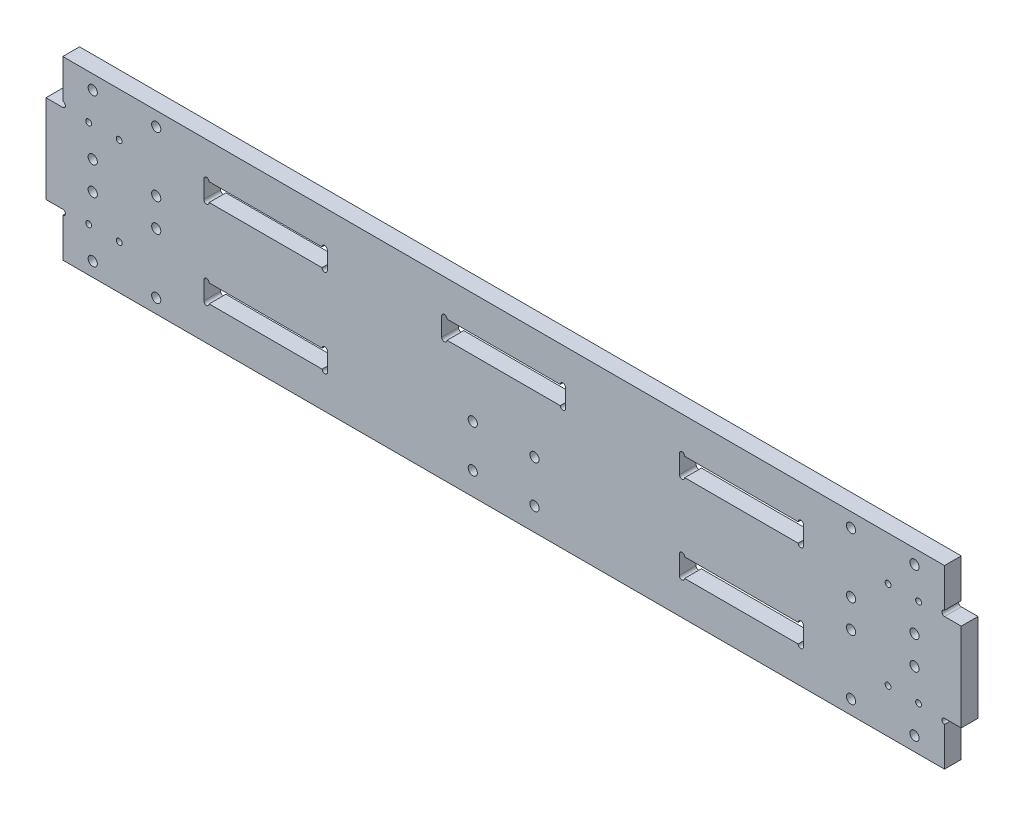
from build123d import *

# Parameters (mm, degrees)
SKETCH1_R                  = 2.6
SKETCH1_W                  = 70
SKETCH1_H                  = 10.2
SKETCH1_W_2                = 70.1
SKETCH1_H_2                = 10.3
SKETCH1_W_3                = 70.2
SKETCH1_H_3                = 10.4
SKETCH1_W_4                = 70.3
SKETCH1_H_4                = 10.5
SKETCH1_W_5                = 70.4
SKETCH1_H_5                = 10.6
BOSS_EXTRUDE1_DEPTH        = 9.5
F_3_3_3_3_DIAMETER_HOLE1_D = 3.3
F_3_0_3_DIAMETER_HOLE1_D   = 3


with BuildPart() as part:
    # Sketch1 → Boss-Extrude1 (new body)
    with BuildSketch(Plane.XY):
        Polygon((-250, -25), (-259.5, -25), (-259.5, 25), (-250, 25), (-250, 50), (250, 50), (250, 25), (259.5, 25), (259.5, -25), (250, -25), (250, -50), (-250, -50), align=None)
        with Locations((-233, -42)):
            Circle(SKETCH1_R, mode=Mode.SUBTRACT)
        with Locations((-197, -42)):
            Circle(SKETCH1_R, mode=Mode.SUBTRACT)
        with Locations((-197, -8)):
            Circle(SKETCH1_R, mode=Mode.SUBTRACT)
        with Locations((-233, -8)):
            Circle(SKETCH1_R, mode=Mode.SUBTRACT)
        with Locations((-197, 42)):
            Circle(SKETCH1_R, mode=Mode.SUBTRACT)
        with Locations((-197, 8)):
            Circle(SKETCH1_R, mode=Mode.SUBTRACT)
        with Locations((-233, 8)):
            Circle(SKETCH1_R, mode=Mode.SUBTRACT)
        with Locations((-233, 42)):
            Circle(SKETCH1_R, mode=Mode.SUBTRACT)
        with Locations((233, 42)):
            Circle(SKETCH1_R, mode=Mode.SUBTRACT)
        with Locations((233, 8)):
            Circle(SKETCH1_R, mode=Mode.SUBTRACT)
        with Locations((197, 8)):
            Circle(SKETCH1_R, mode=Mode.SUBTRACT)
        with Locations((197, 42)):
            Circle(SKETCH1_R, mode=Mode.SUBTRACT)
        with Locations((233, -8)):
            Circle(SKETCH1_R, mode=Mode.SUBTRACT)
        with Locations((197, -8)):
            Circle(SKETCH1_R, mode=Mode.SUBTRACT)
        with Locations((197, -42)):
            Circle(SKETCH1_R, mode=Mode.SUBTRACT)
        with Locations((233, -42)):
            Circle(SKETCH1_R, mode=Mode.SUBTRACT)
        with Locations((-17.5, -37)):
            Circle(SKETCH1_R, mode=Mode.SUBTRACT)
        with Locations((17.5, -37)):
            Circle(SKETCH1_R, mode=Mode.SUBTRACT)
        with Locations((17.5, -13)):
            Circle(SKETCH1_R, mode=Mode.SUBTRACT)
        with Locations((-17.5, -13)):
            Circle(SKETCH1_R, mode=Mode.SUBTRACT)
        with Locations((-135, 24.9)):
            Rectangle(SKETCH1_W, SKETCH1_H, mode=Mode.SUBTRACT)
        with Locations((-134.95, -24.85)):
            Rectangle(SKETCH1_W_2, SKETCH1_H_2, mode=Mode.SUBTRACT)
        with Locations((0, 24.8)):
            Rectangle(SKETCH1_W_3, SKETCH1_H_3, mode=Mode.SUBTRACT)
        with Locations((134.85, 24.75)):
            Rectangle(SKETCH1_W_4, SKETCH1_H_4, mode=Mode.SUBTRACT)
        with Locations((134.8, -24.7)):
            Rectangle(SKETCH1_W_5, SKETCH1_H_5, mode=Mode.SUBTRACT)
    extrude(amount=BOSS_EXTRUDE1_DEPTH)

    # Ø3.3 (3.3) Diameter Hole1 (through all)
    with Locations(Plane.XY.offset(9.5)):
        with Locations((-235.3, 25), (-218, 25), (-218, -25), (-235.3, -25), (235.3, -25), (218, -25), (218, 25), (235.3, 25)):
            Hole(F_3_3_3_3_DIAMETER_HOLE1_D / 2)

    # Ø3.0 (3) Diameter Hole1 (through all)
    with Locations(Plane.XY.offset(9.5)):
        with Locations((-250, 26.5), (-250, -26.5), (-168.5, 30), (-101.5, 30), (-101.5, 19.8), (-168.5, 19.8), (-168.5, -19.7), (-168.5, -30), (-101.4, -19.7), (-101.4, -30), (-33.6, 30), (-33.6, 19.6), (33.6, 30), (33.6, 19.6), (168.5, 30), (168.5, 19.5), (101.2, 30), (101.2, 19.5), (101.1, -19.4), (101.1, -30), (168.5, -19.4), (168.5, -30), (250, 26.5), (250, -26.5)):
            Hole(F_3_0_3_DIAMETER_HOLE1_D / 2)


solid = part.part
